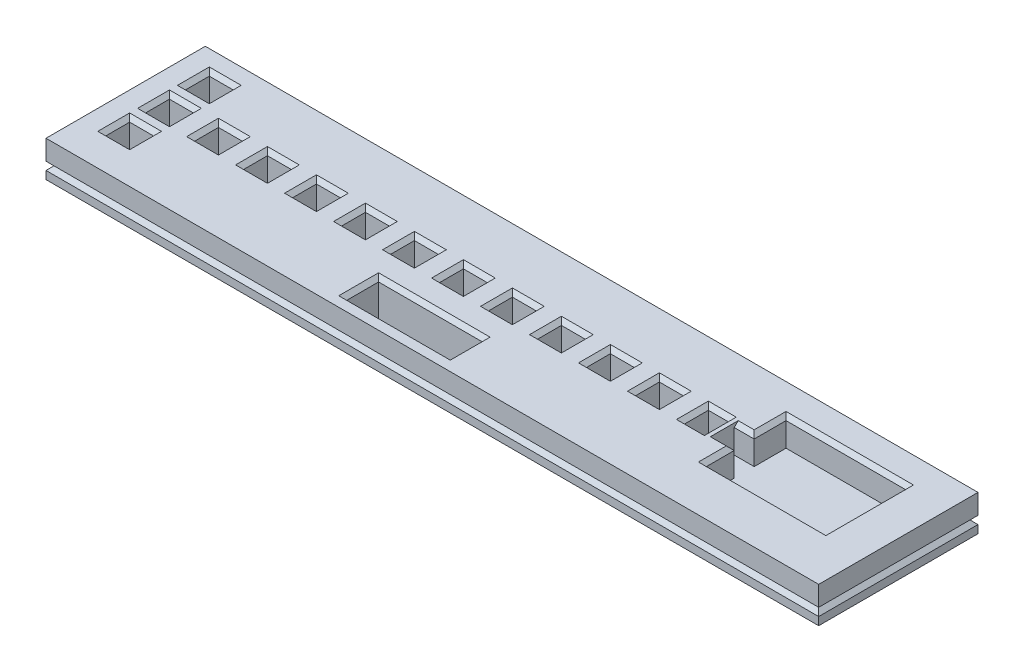
from build123d import *

# Parameters (mm, degrees)
SKETCH1_W           = 194
SKETCH1_H           = 40
BOSS_EXTRUDE1_DEPTH = 10
SKETCH3_W           = 6
SKETCH3_H           = 6
SKETCH3_W_2         = 26
SKETCH3_H_2         = 8
CUT_EXTRUDE1_DEPTH  = 11
CHAMFER1_SIZE       = 1
CHAMFER2_SIZE       = 1
SKETCH4_W           = 5
SKETCH4_H           = 5
CUT_EXTRUDE2_DEPTH  = 7
CHAMFER3_SIZE       = 1
CUT_EXTRUDE4_DEPTH  = 195
CUT_EXTRUDE5_DEPTH  = 41


with BuildPart() as part:
    # Sketch1 → Boss-Extrude1 (new body)
    with BuildSketch(Plane(origin=(0, 0, 0), x_dir=(1, 0, 0), z_dir=(0, 1, 0))):
        Rectangle(SKETCH1_W, SKETCH1_H)
    extrude(amount=BOSS_EXTRUDE1_DEPTH)

    # Sketch3 → Cut-Extrude1 (cut, through all)
    with BuildSketch(Plane(origin=(0, 10, 0), x_dir=(1, 0, 0), z_dir=(0, 1, 0))):
        with Locations((-88, 2)):
            Rectangle(SKETCH3_W, SKETCH3_H)
        with Locations((-75.7, 2)):
            Rectangle(SKETCH3_W, SKETCH3_H)
        with Locations((-63.4, 2)):
            Rectangle(SKETCH3_W, SKETCH3_H)
        with Locations((-51.1, 2)):
            Rectangle(SKETCH3_W, SKETCH3_H)
        with Locations((-38.8, 2)):
            Rectangle(SKETCH3_W, SKETCH3_H)
        with Locations((-26.5, 2)):
            Rectangle(SKETCH3_W, SKETCH3_H)
        with Locations((-14.2, 2)):
            Rectangle(SKETCH3_W, SKETCH3_H)
        with Locations((-1.9, 2)):
            Rectangle(SKETCH3_W, SKETCH3_H)
        with Locations((10.4, 2)):
            Rectangle(SKETCH3_W, SKETCH3_H)
        with Locations((22.7, 2)):
            Rectangle(SKETCH3_W, SKETCH3_H)
        with Locations((35, 2)):
            Rectangle(SKETCH3_W, SKETCH3_H)
        with Locations((47.3, 2)):
            Rectangle(SKETCH3_W, SKETCH3_H)
        with Locations((-88, 12)):
            Rectangle(SKETCH3_W, SKETCH3_H)
        with Locations((-88, -8)):
            Rectangle(SKETCH3_W, SKETCH3_H)
        with Locations((-12, -12.5)):
            Rectangle(SKETCH3_W_2, SKETCH3_H_2)
    extrude(amount=-CUT_EXTRUDE1_DEPTH, mode=Mode.SUBTRACT)

    # Chamfer1
    chamfer1_edges = [part.edges().sort_by_distance(p)[0] for p in [
        (-26.5, 10, -5),
        (-29.5, 10, -2),
        (-14.2, 10, 1),
        (-11.2, 10, -2),
        (-14.2, 10, -5),
        (-17.2, 10, -2),
        (-1.9, 10, 1),
        (1.1, 10, -2),
        (-1.9, 10, -5),
        (-4.9, 10, -2),
        (10.4, 10, 1),
        (13.4, 10, -2),
        (10.4, 10, -5),
        (7.4, 10, -2),
        (1, 10, 12.5),
        (-12, 10, 8.5),
        (-25, 10, 12.5),
        (-12, 10, 16.5),
        (-88, 10, -9),
        (-85, 10, -12),
        (-88, 10, -15),
        (-91, 10, -12),
        (22.7, 10, 1),
        (25.7, 10, -2),
        (22.7, 10, -5),
        (19.7, 10, -2),
        (35, 10, 1),
        (38, 10, -2),
        (35, 10, -5),
        (32, 10, -2),
        (47.3, 10, 1),
        (47.3, 10, -5),
        (44.3, 10, -2),
        (-88, 10, 11),
        (-85, 10, 8),
        (-88, 10, 5),
        (-91, 10, 8),
        (-85, 10, -2),
        (-88, 10, -5),
        (-91, 10, -2),
        (-88, 10, 1),
        (-75.7, 10, 1),
        (-72.7, 10, -2),
        (-75.7, 10, -5),
        (-78.7, 10, -2),
        (-63.4, 10, 1),
        (-60.4, 10, -2),
        (-63.4, 10, -5),
        (-66.4, 10, -2),
        (-51.1, 10, 1),
        (-48.1, 10, -2),
        (-51.1, 10, -5),
        (-54.1, 10, -2),
        (-38.8, 10, 1),
        (-35.8, 10, -2),
        (-38.8, 10, -5),
        (-41.8, 10, -2),
        (-26.5, 10, 1),
        (-23.5, 10, -2),
    ]]
    chamfer(chamfer1_edges, length=CHAMFER1_SIZE)

    # Chamfer2
    chamfer2_edges = [part.edges().sort_by_distance(p)[0] for p in [
        (-14.2, 0, 1),
        (-17.2, 0, -2),
        (-14.2, 0, -5),
        (-11.2, 0, -2),
        (-1.9, 0, 1),
        (-4.9, 0, -2),
        (-1.9, 0, -5),
        (1.1, 0, -2),
        (10.4, 0, 1),
        (7.4, 0, -2),
        (10.4, 0, -5),
        (13.4, 0, -2),
        (1, 0, 12.5),
        (-12, 0, 16.5),
        (-25, 0, 12.5),
        (-12, 0, 8.5),
        (-88, 0, -9),
        (-91, 0, -12),
        (-88, 0, -15),
        (-85, 0, -12),
        (22.7, 0, 1),
        (19.7, 0, -2),
        (22.7, 0, -5),
        (25.7, 0, -2),
        (35, 0, 1),
        (32, 0, -2),
        (35, 0, -5),
        (38, 0, -2),
        (47.3, 0, 1),
        (44.3, 0, -2),
        (47.3, 0, -5),
        (50.3, 0, -2),
        (-88, 0, 11),
        (-91, 0, 8),
        (-88, 0, 5),
        (-85, 0, 8),
        (-85, 0, -2),
        (-88, 0, 1),
        (-91, 0, -2),
        (-88, 0, -5),
        (0, 0, 20),
        (-97, 0, 0),
        (0, 0, -20),
        (97, 0, 0),
        (-75.7, 0, 1),
        (-78.7, 0, -2),
        (-75.7, 0, -5),
        (-72.7, 0, -2),
        (-63.4, 0, 1),
        (-66.4, 0, -2),
        (-63.4, 0, -5),
        (-60.4, 0, -2),
        (-51.1, 0, 1),
        (-54.1, 0, -2),
        (-51.1, 0, -5),
        (-48.1, 0, -2),
        (-38.8, 0, 1),
        (-41.8, 0, -2),
        (-38.8, 0, -5),
        (-35.8, 0, -2),
        (-26.5, 0, 1),
        (-29.5, 0, -2),
        (-26.5, 0, -5),
        (-23.5, 0, -2),
    ]]
    chamfer(chamfer2_edges, length=CHAMFER2_SIZE)

    # Sketch4 → Cut-Extrude2 (cut)
    with BuildSketch(Plane(origin=(0, 10, 0), x_dir=(1, 0, 0), z_dir=(0, 1, 0))):
        with Locations((53.8, 2)):
            Rectangle(SKETCH4_W, SKETCH4_H)
        Polygon((56.3, 12.5), (56.3, 4.5), (56.3, -0.5), (56.3, -7.5), (86.3, -7.5), (86.3, 12.5), align=None)
    extrude(amount=-CUT_EXTRUDE2_DEPTH, mode=Mode.SUBTRACT)

    # Chamfer3
    chamfer3_edges = [part.edges().sort_by_distance(p)[0] for p in [
        (53.8, 10, -4.5),
        (71.3, 10, -12.5),
        (86.3, 10, -2.5),
        (53.8, 10, 0.5),
        (56.3, 10, 4),
        (71.3, 10, 7.5),
        (56.3, 10, -8.5),
    ]]
    chamfer(chamfer3_edges, length=CHAMFER3_SIZE)

    # Sketch6 → Cut-Extrude4 (cut, through all)
    with BuildSketch(Plane.ZY.offset(97)):
        Polygon((-20, 5), (-20, 3), (-19, 4), align=None)
        Polygon((19, 4), (20, 5), (20, 3), align=None)
    extrude(amount=-CUT_EXTRUDE4_DEPTH, mode=Mode.SUBTRACT)

    # Sketch7 → Cut-Extrude5 (cut, through all)
    with BuildSketch(Plane.XY.offset(20)):
        Polygon((-97, 5), (-96, 4), (-97, 3), align=None)
        Polygon((96, 4), (97, 3), (97, 5), align=None)
    extrude(amount=-CUT_EXTRUDE5_DEPTH, mode=Mode.SUBTRACT)


solid = part.part
